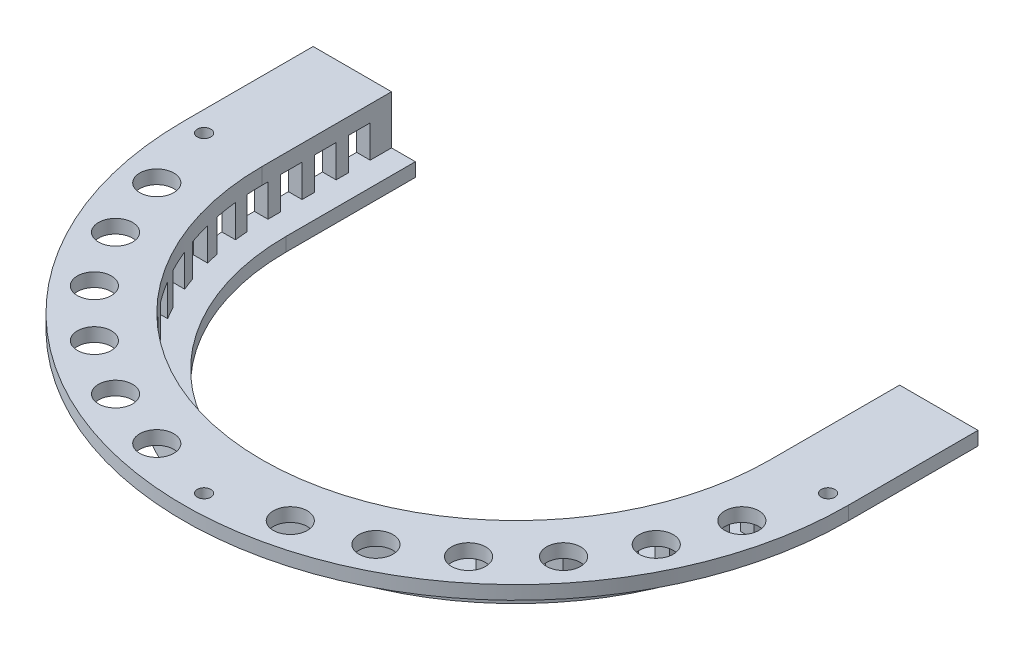
from build123d import *

# Parameters (mm, degrees)
REVOLVE1_ANGLE      = 180
BOSS_EXTRUDE1_DEPTH = 38
BOSS_EXTRUDE2_DEPTH = 38
SKETCH4_R           = 2
SKETCH4_R_2         = 5
CUT_EXTRUDE1_DEPTH  = 139.696209821
SKETCH5_W           = 6.35
SKETCH5_H           = 9.5
CUT_EXTRUDE2_DEPTH  = 202.823634998


with BuildPart() as part:
    # Sketch1 → Revolve1 (revolve)
    with BuildSketch(Plane.XY):
        Polygon((-74.551832937, 0), (-74.551832937, 14.28), (-78.551832937, 14.28), (-97.551832937, 14.28), (-97.551832937, 10.28), (-78.551832937, 10.28), (-78.551832937, -4), (-67.551832937, -4), (-67.551832937, 0), align=None)
    revolve(axis=Axis((0, 0, 0), (0, 1, 0)), revolution_arc=REVOLVE1_ANGLE)

    # Sketch3 → Boss-Extrude1 (add)
    with BuildSketch(Plane(origin=(0, 0, 0), x_dir=(-1, 0, 0), z_dir=(0, 0, -1))):
        Polygon((-97.551832937, 14.28), (-74.551832937, 14.28), (-74.551832937, 0), (-67.551832937, 0), (-67.551832937, -4), (-78.551832937, -4), (-78.551832937, 10.28), (-97.551832937, 10.28), align=None)
    extrude(amount=BOSS_EXTRUDE1_DEPTH)

    # Sketch1_2 → Boss-Extrude2 (add)
    with BuildSketch(Plane.XY):
        Polygon((-74.551832937, 0), (-74.551832937, 14.28), (-78.551832937, 14.28), (-97.551832937, 14.28), (-97.551832937, 10.28), (-78.551832937, 10.28), (-78.551832937, -4), (-67.551832937, -4), (-67.551832937, 0), align=None)
    extrude(amount=-BOSS_EXTRUDE2_DEPTH)

    # Sketch4 → Cut-Extrude1 (cut, through all)
    with BuildSketch(Plane(origin=(0, 10.28, 0), x_dir=(-1, 0, 0), z_dir=(0, -1, 0))):
        with Locations((0, -91.551832937)):
            Circle(SKETCH4_R)
        with Locations((-91.551832937, 0)):
            Circle(SKETCH4_R)
        with Locations((91.551832937, 0)):
            Circle(SKETCH4_R)
        with Locations((85.844189649, -19.593376102)):
            Circle(SKETCH4_R_2)
        with Locations((79.331960238, -38.204258511)):
            Circle(SKETCH4_R_2)
        with Locations((68.841695079, -54.899419871)):
            Circle(SKETCH4_R_2)
        with Locations((54.899419871, -68.841695079)):
            Circle(SKETCH4_R_2)
        with Locations((38.204258511, -79.331960238)):
            Circle(SKETCH4_R_2)
        with Locations((19.593376102, -85.844189649)):
            Circle(SKETCH4_R_2)
        with Locations((-19.593376102, -85.844189649)):
            Circle(SKETCH4_R_2)
        with Locations((-38.204258511, -79.331960238)):
            Circle(SKETCH4_R_2)
        with Locations((-54.899419871, -68.841695079)):
            Circle(SKETCH4_R_2)
        with Locations((-68.841695079, -54.899419871)):
            Circle(SKETCH4_R_2)
        with Locations((-79.331960238, -38.204258511)):
            Circle(SKETCH4_R_2)
        with Locations((-85.844189649, -19.593376102)):
            Circle(SKETCH4_R_2)
    extrude(amount=-CUT_EXTRUDE1_DEPTH, mode=Mode.SUBTRACT)

    # Sketch5 → Cut-Extrude2 (cut, through all)
    with BuildSketch(Plane(origin=(78.551832937, 0, 0), x_dir=(0, 0, -1), z_dir=(1, 0, 0))):
        with Locations((28.575, 4.75)):
            Rectangle(SKETCH5_W, SKETCH5_H)
        with Locations((18.575, 4.75)):
            Rectangle(SKETCH5_W, SKETCH5_H)
        with Locations((8.575, 4.75)):
            Rectangle(SKETCH5_W, SKETCH5_H)
        with Locations((-1.425, 4.75)):
            Rectangle(SKETCH5_W, SKETCH5_H)
        with Locations((-11.425, 4.75)):
            Rectangle(SKETCH5_W, SKETCH5_H)
        with Locations((-21.425, 4.75)):
            Rectangle(SKETCH5_W, SKETCH5_H)
        with Locations((-31.425, 4.75)):
            Rectangle(SKETCH5_W, SKETCH5_H)
        with Locations((-41.425, 4.75)):
            Rectangle(SKETCH5_W, SKETCH5_H)
        with Locations((-51.425, 4.75)):
            Rectangle(SKETCH5_W, SKETCH5_H)
        with Locations((-61.425, 4.75)):
            Rectangle(SKETCH5_W, SKETCH5_H)
    extrude(amount=-CUT_EXTRUDE2_DEPTH, mode=Mode.SUBTRACT)


solid = part.part
